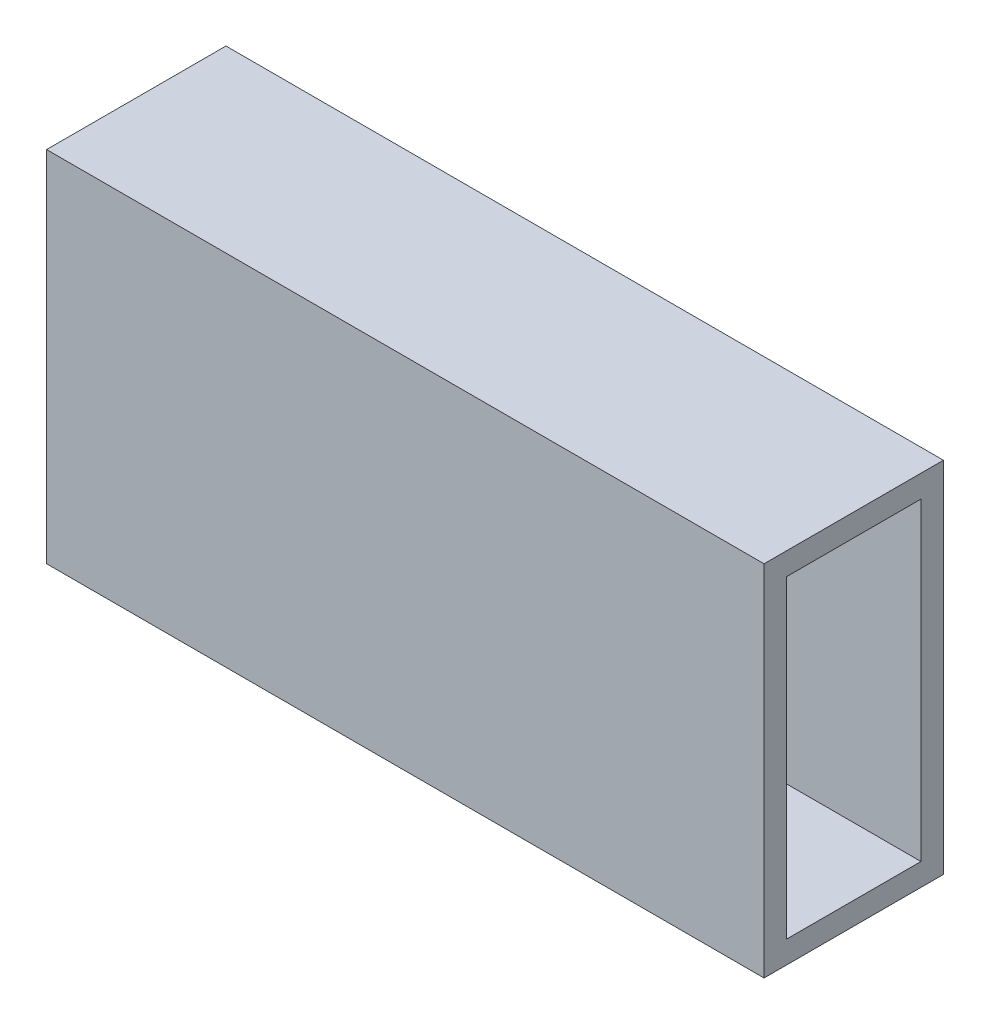
from build123d import *

# Parameters (mm, degrees)
SKETCH1_W           = 25.4
SKETCH1_H           = 50.8
SKETCH1_W_2         = 19.05
SKETCH1_H_2         = 44.45
BOSS_EXTRUDE1_DEPTH = 254
CUT_EXTRUDE1_DEPTH  = 149.098


with BuildPart() as part:
    # Sketch1 → Boss-Extrude1 (new body)
    with BuildSketch(Plane(origin=(0, 0, 0), x_dir=(0, 0, -1), z_dir=(1, 0, 0))):
        with Locations((12.7, 25.4)):
            Rectangle(SKETCH1_W, SKETCH1_H)
        with Locations((12.7, 25.4)):
            Rectangle(SKETCH1_W_2, SKETCH1_H_2, mode=Mode.SUBTRACT)
    extrude(amount=BOSS_EXTRUDE1_DEPTH)

    # Sketch2 → Cut-Extrude1 (cut)
    with BuildSketch(Plane(origin=(0, 0, -25.4), x_dir=(-1, 0, 0), z_dir=(0, 0, -1))):
        Polygon((-152.4, 23.345366578), (-152.4, 0), (0, 0), (0, 50.8), (-152.4, 50.8), align=None)
    extrude(amount=-CUT_EXTRUDE1_DEPTH, mode=Mode.SUBTRACT)


solid = part.part
